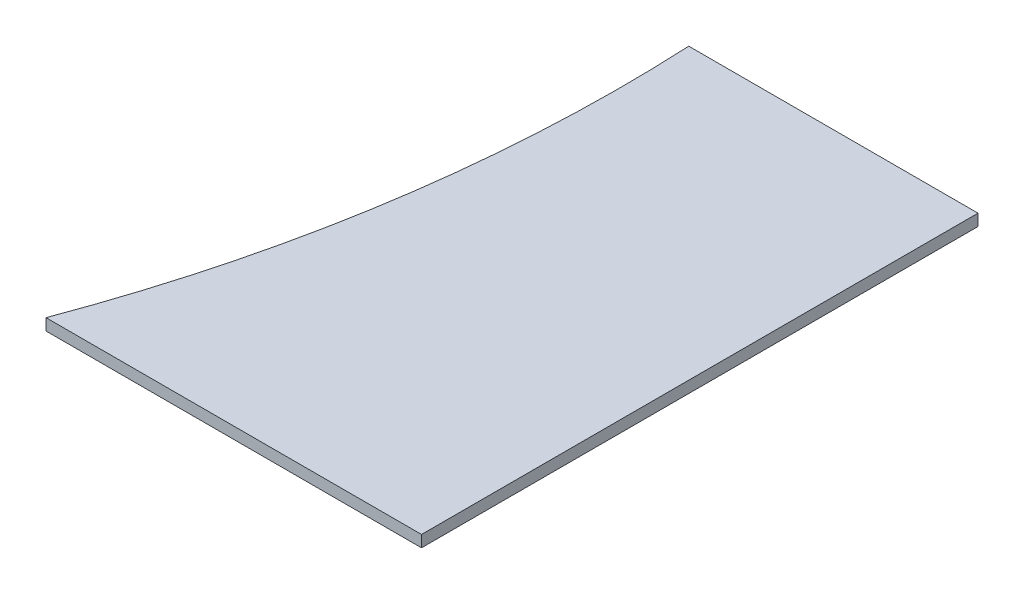
from build123d import *

# Parameters (mm, degrees)
BOSS_EXTRUDE2_DEPTH = 3.175


with BuildPart() as part:
    # Sketch2 → Boss-Extrude2 (new body)
    with BuildSketch(Plane(origin=(0, 0, 0), x_dir=(1, 0, 0), z_dir=(0, 1, 0))):
        with BuildLine():
            Line((-39.37, 76.2), (-39.846548029, 76.2))
            ThreePointArc((-39.846548029, 76.2), (-43.865843386, -1.207690599), (-63.468364392, -76.2))
            Line((-63.468364392, -76.2), (-39.37, -76.2))
            Line((-39.37, -76.2), (39.37, -76.2))
            Line((39.37, -76.2), (39.37, 76.2))
            Line((39.37, 76.2), (-39.37, 76.2))
        make_face()
    extrude(amount=BOSS_EXTRUDE2_DEPTH)


solid = part.part
